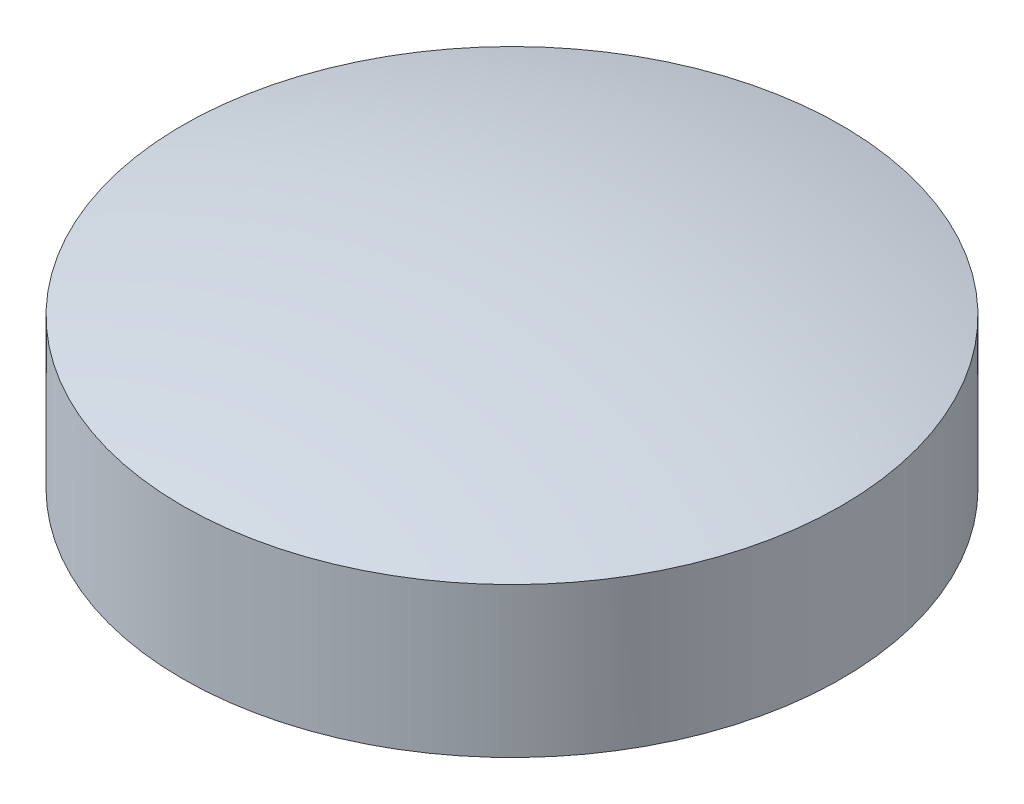
from build123d import *

# Parameters (mm, degrees)
SKETCH2_R          = 1.5
CUT_EXTRUDE1_DEPTH = 5


with BuildPart() as part:
    # Sketch1 → Revolve1 (revolve)
    with BuildSketch(Plane.XY):
        with BuildLine():
            Line((0, 13), (0, 0))
            Line((0, 0), (22, 0))
            Line((22, 0), (22, 10))
            ThreePointArc((22, 10), (11.101801656, 12.246545474), (0, 13))
        make_face()
    revolve(axis=Axis((0, 48.764702031, 0), (0, -1, 0)))

    # Sketch2 → Cut-Extrude1 (cut)
    with BuildSketch(Plane.XZ):
        with Locations((-22, 0)):
            Circle(SKETCH2_R)
    extrude(amount=-CUT_EXTRUDE1_DEPTH, mode=Mode.SUBTRACT)


solid = part.part
